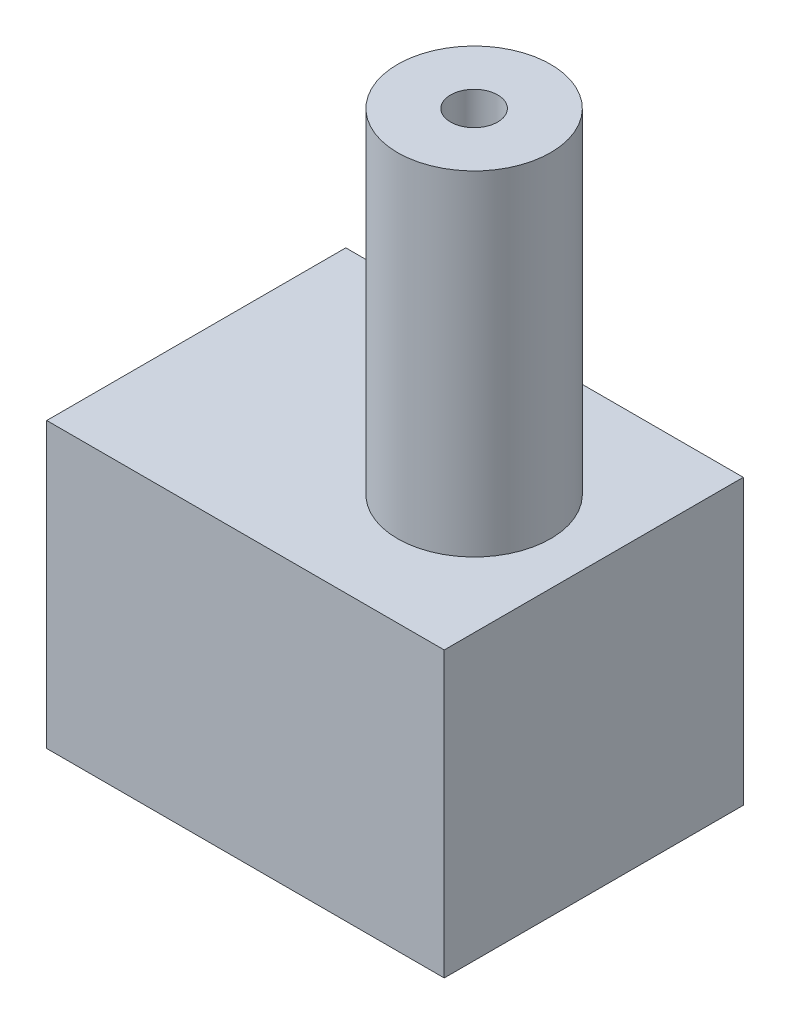
from build123d import *

# Parameters (mm, degrees)
SKETCH1_W           = 16.88
SKETCH1_H           = 12.7
BOSS_EXTRUDE1_DEPTH = 12.065
SKETCH3_R           = 3.25
BOSS_EXTRUDE2_DEPTH = 14.2
SKETCH4_R           = 1
CUT_EXTRUDE1_DEPTH  = 27.265


with BuildPart() as part:
    # Sketch1 → Boss-Extrude1 (new body)
    with BuildSketch(Plane(origin=(0, 0, 0), x_dir=(1, 0, 0), z_dir=(0, 1, 0))):
        with Locations((8.44, 6.35)):
            Rectangle(SKETCH1_W, SKETCH1_H)
    extrude(amount=BOSS_EXTRUDE1_DEPTH)

    # Sketch3 → Boss-Extrude2 (add)
    with BuildSketch(Plane(origin=(0, 12.065, 0), x_dir=(1, 0, 0), z_dir=(0, 1, 0))):
        with Locations((11.8, 6.35)):
            Circle(SKETCH3_R)
    extrude(amount=BOSS_EXTRUDE2_DEPTH)

    # Sketch4 → Cut-Extrude1 (cut, through all)
    with BuildSketch(Plane(origin=(0, 26.265, 0), x_dir=(1, 0, 0), z_dir=(0, 1, 0))):
        with Locations((11.8, 6.35)):
            Circle(SKETCH4_R)
    extrude(amount=-CUT_EXTRUDE1_DEPTH, mode=Mode.SUBTRACT)


solid = part.part
